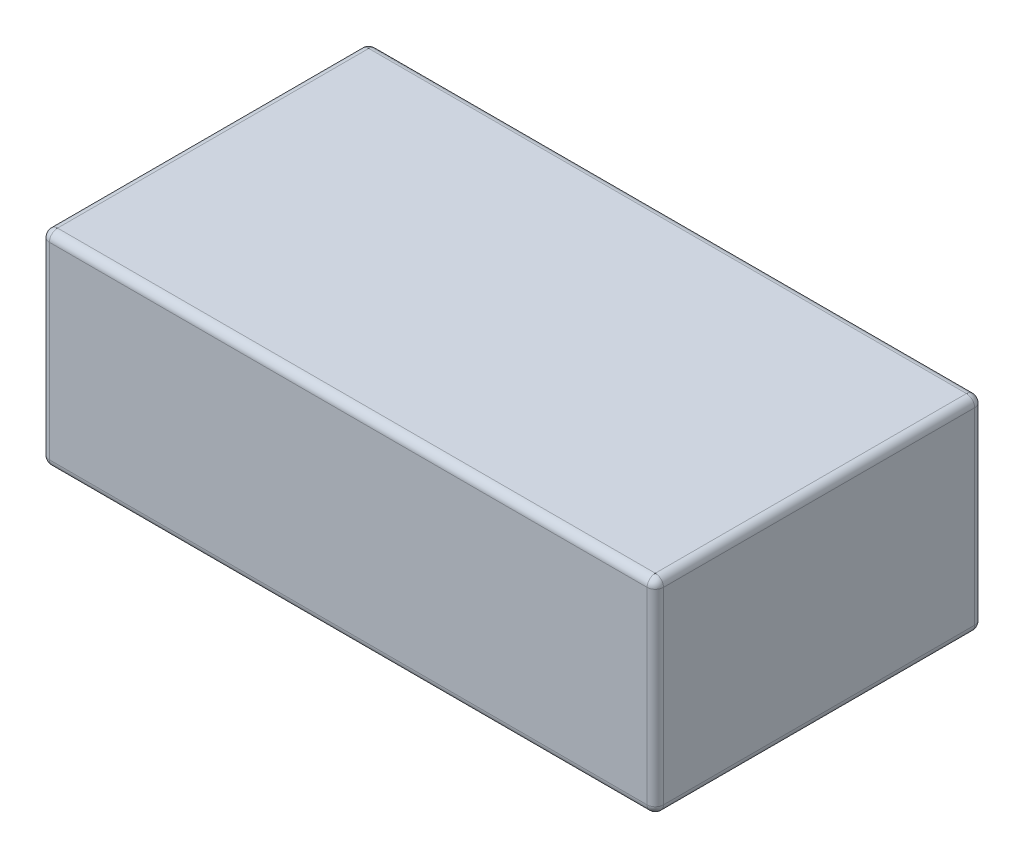
from build123d import *

# Parameters (mm, degrees)
BOSS_EXTRUDE1_DEPTH = 0.25
FILLET2_R           = 0.02


with BuildPart() as part:
    # Sketch1 → Boss-Extrude1 (new body, symmetric)
    with BuildSketch(Plane(origin=(0, 0, 0), x_dir=(1, 0, 0), z_dir=(0, 1, 0))):
        with BuildLine():
            Line((-0.73, -0.4), (0.73, -0.4))
            ThreePointArc((0.73, -0.4), (0.744142136, -0.394142136), (0.75, -0.38))
            Line((0.75, -0.38), (0.75, 0.38))
            ThreePointArc((0.75, 0.38), (0.744142136, 0.394142136), (0.73, 0.4))
            Line((0.73, 0.4), (-0.73, 0.4))
            ThreePointArc((-0.73, 0.4), (-0.744142136, 0.394142136), (-0.75, 0.38))
            Line((-0.75, 0.38), (-0.75, -0.38))
            ThreePointArc((-0.75, -0.38), (-0.744142136, -0.394142136), (-0.73, -0.4))
        make_face()
    extrude(amount=BOSS_EXTRUDE1_DEPTH, both=True)

    # Fillet2
    fillet2_edges = [part.edges().sort_by_distance(p)[0] for p in [
        (0.744142136, 0.25, 0.394142136),
        (0, -0.25, 0.4),
        (-0.744142136, -0.25, 0.394142136),
        (0.75, 0.25, 0),
        (0.744142136, 0.25, -0.394142136),
        (0, 0.25, -0.4),
        (-0.744142136, 0.25, -0.394142136),
        (-0.75, 0.25, 0),
        (-0.744142136, 0.25, 0.394142136),
        (0, 0.25, 0.4),
        (-0.75, -0.25, 0),
        (-0.744142136, -0.25, -0.394142136),
        (0, -0.25, -0.4),
        (0.744142136, -0.25, -0.394142136),
        (0.75, -0.25, 0),
        (0.744142136, -0.25, 0.394142136),
    ]]
    fillet(fillet2_edges, radius=FILLET2_R)


solid = part.part
